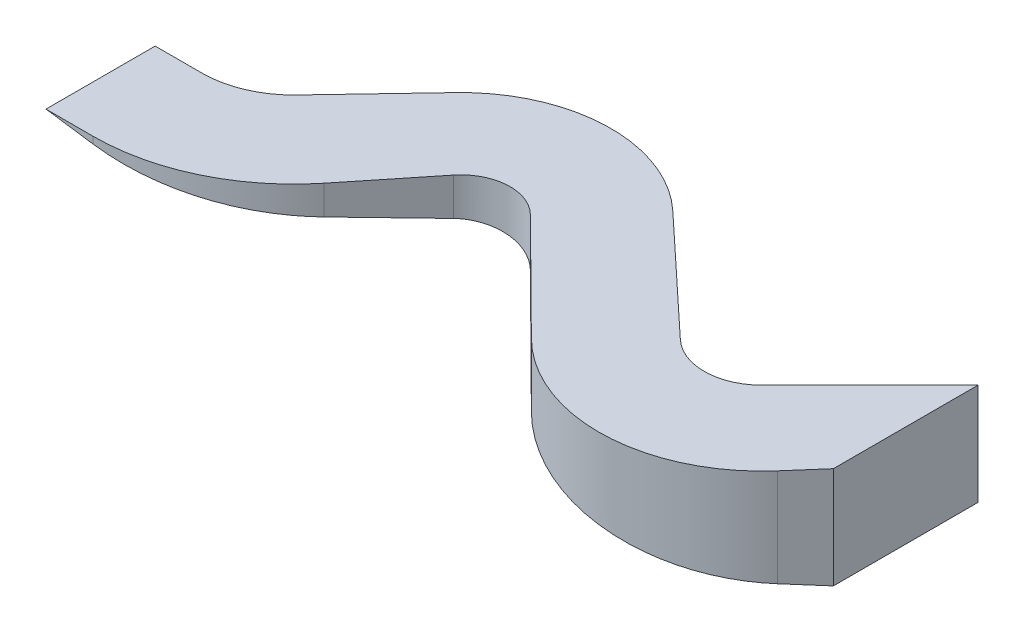
from build123d import *

# Parameters (mm, degrees)
BOSS_EXTRUDE3_DEPTH     = 600
CUT_EXTRUDE1_DEPTH      = 2000
CUT_EXTRUDE1_DEPTH_BACK = 2000


with BuildPart() as part:
    # Sketch1 → Boss-Extrude3 (new body)
    with BuildSketch(Plane(origin=(0, 0, 0), x_dir=(1, 0, 0), z_dir=(0, 1, 0))):
        with BuildLine():
            Line((0, 0), (0, -854.33))
            Line((0, -854.33), (-154.190463005, -1030.847317622))
            ThreePointArc((-154.190463005, -1030.847317622), (-844.751743063, -1359.661426587), (-1557.162523479, -1081.337012069))
            Line((-1557.162523479, -1081.337012069), (-2194.051488263, -450.19764079))
            ThreePointArc((-2194.051488263, -450.19764079), (-2414.513161537, -366.64657948), (-2624.180140047, -474.460712836))
            Line((-2624.180140047, -474.460712836), (-2964.859106314, -898.139677134))
            ThreePointArc((-2964.859106314, -898.139677134), (-3376.288360318, -1224.211199414), (-3888.216806642, -1340.512250728))
            Line((-3888.216806642, -1340.512250728), (-4165.384496326, -1340.512250728))
            Line((-4165.384496326, -1340.512250728), (-4165.384496326, -695.670559359))
            Line((-4165.384496326, -695.670559359), (-3888.216806642, -695.670559359))
            ThreePointArc((-3888.216806642, -695.670559359), (-3675.041307945, -651.811876682), (-3496.493944625, -527.360214008))
            Line((-3496.493944625, -527.360214008), (-3040.463363472, -46.750645832))
            ThreePointArc((-3040.463363472, -46.750645832), (-2424.707007304, 228.819562259), (-1793.551427485, -9.376709356))
            Line((-1793.551427485, -9.376709356), (-1112.126726764, -646.363592415))
            ThreePointArc((-1112.126726764, -646.363592415), (-873.640525372, -738.159045255), (-638.381938968, -638.381938968))
            Line((-638.381938968, -638.381938968), (0, 0))
        make_face()
    extrude(amount=BOSS_EXTRUDE3_DEPTH)

    # Sketch2 → Cut-Extrude1 (cut, two sides)
    with BuildSketch(Plane.XY) as cut_extrude1_sk:
        Polygon((-4165.384496326, 600), (0, 0), (-4165.384496326, 0), align=None)
    extrude(amount=CUT_EXTRUDE1_DEPTH, mode=Mode.SUBTRACT)
    extrude(cut_extrude1_sk.sketch, amount=-CUT_EXTRUDE1_DEPTH_BACK, mode=Mode.SUBTRACT)


solid = part.part
